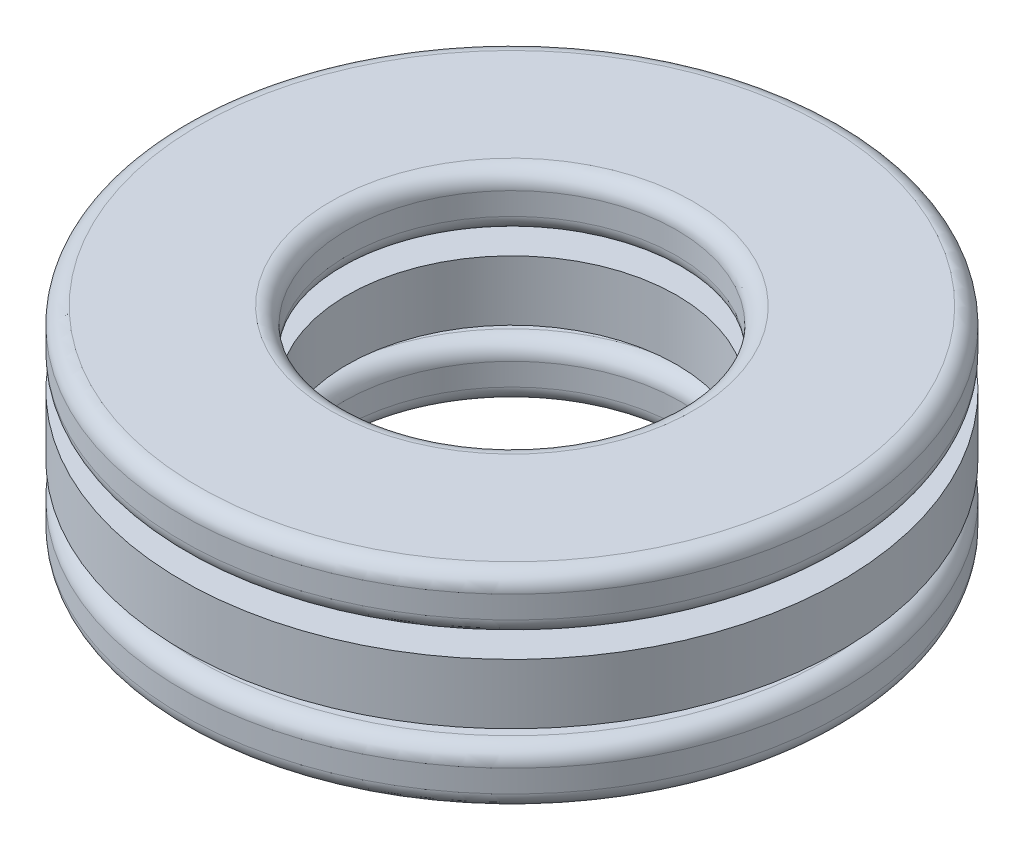
from build123d import *

# Parameters (mm, degrees)
SKETCH1_W         = 4
SKETCH1_H         = 1.458333334
CIRPATTERN1_COUNT = 6
CIRPATTERN1_ANGLE = 300
CIRPATTERN2_COUNT = 6


with BuildPart() as part:
    # Sketch1 → Revolve1 (revolve)
    with BuildSketch(Plane(origin=(0, 0, 0), x_dir=(0, 0, -1), z_dir=(1, 0, 0))):
        with Locations((-6, 0)):
            Rectangle(SKETCH1_W, SKETCH1_H)
    revolve(axis=Axis((0, -3.5, 0), (0, 1, 0)))

    # Sketch3 → Cut-Revolve1 (revolve, cut)
    with BuildSketch(Plane(origin=(0, 0, 0), x_dir=(0, 0, -1), z_dir=(1, 0, 0))):
        with BuildLine():
            Line((-6, 1.166666667), (-6, -1.166666667))
            ThreePointArc((-6, -1.166666667), (-7.166666667, 0), (-6, 1.166666667))
        make_face()
    cut_revolve1 = revolve(axis=Axis((0, 1.166666667, 6), (0, -1, 0)), mode=Mode.SUBTRACT)

    # CirPattern2: Cut-Revolve1 ×6 about axis
    cirpattern2_axis = Axis((0, 0, 0), (0, 1, 0))
    for i in range(1, CIRPATTERN2_COUNT):
        add(cut_revolve1.rotate(cirpattern2_axis, i * 360 / CIRPATTERN2_COUNT), mode=Mode.SUBTRACT)


with BuildPart() as body_2:
    # Sketch2 → Revolve2 (revolve)
    with BuildSketch(Plane(origin=(0, 0, 0), x_dir=(0, 0, -1), z_dir=(1, 0, 0))):
        with BuildLine():
            Line((-6, 1.166666667), (-6, -1.166666667))
            ThreePointArc((-6, -1.166666667), (-7.166666667, 0), (-6, 1.166666667))
        make_face()
    revolve(axis=Axis((0, 1.166666667, 6), (0, -1, 0)))


with BuildPart() as cirpattern1_1:
    # CirPattern1: pattern copy
    add(body_2.part.rotate(Axis((0, 3.5, 0), (0, -1, 0)), 1 * CIRPATTERN1_ANGLE / (CIRPATTERN1_COUNT - 1)))


with BuildPart() as cirpattern1_2:
    # CirPattern1: pattern copy
    add(body_2.part.rotate(Axis((0, 3.5, 0), (0, -1, 0)), 2 * CIRPATTERN1_ANGLE / (CIRPATTERN1_COUNT - 1)))


with BuildPart() as cirpattern1_3:
    # CirPattern1: pattern copy
    add(body_2.part.rotate(Axis((0, 3.5, 0), (0, -1, 0)), 3 * CIRPATTERN1_ANGLE / (CIRPATTERN1_COUNT - 1)))


with BuildPart() as cirpattern1_4:
    # CirPattern1: pattern copy
    add(body_2.part.rotate(Axis((0, 3.5, 0), (0, -1, 0)), 4 * CIRPATTERN1_ANGLE / (CIRPATTERN1_COUNT - 1)))


with BuildPart() as cirpattern1_5:
    # CirPattern1: pattern copy
    add(body_2.part.rotate(Axis((0, 3.5, 0), (0, -1, 0)), 5 * CIRPATTERN1_ANGLE / (CIRPATTERN1_COUNT - 1)))


with BuildPart() as body_8:
    # Sketch4 → Revolve3 (revolve)
    with BuildSketch(Plane(origin=(0, 0, 0), x_dir=(0, 0, -1), z_dir=(1, 0, 0))):
        with BuildLine():
            Line((-7.6, 2.5), (-4.4, 2.5))
            ThreePointArc((-4.4, 2.5), (-4.117157288, 2.382842712), (-4, 2.1))
            Line((-4, 2.1), (-4, 1.558333333))
            ThreePointArc((-4, 1.558333333), (-4.117157288, 1.275490621), (-4.4, 1.158333333))
            Line((-4.4, 1.158333333), (-7.6, 1.158333333))
            ThreePointArc((-7.6, 1.158333333), (-7.882842712, 1.275490621), (-8, 1.558333333))
            Line((-8, 1.558333333), (-8, 2.1))
            ThreePointArc((-8, 2.1), (-7.882842712, 2.382842712), (-7.6, 2.5))
        make_face()
        with BuildLine():
            Line((-7.6, -2.5), (-4.5, -2.5))
            ThreePointArc((-4.5, -2.5), (-4.217157288, -2.382842712), (-4.1, -2.1))
            Line((-4.1, -2.1), (-4.1, -1.558333333))
            ThreePointArc((-4.1, -1.558333333), (-4.217157288, -1.275490621), (-4.5, -1.158333333))
            Line((-4.5, -1.158333333), (-7.6, -1.158333333))
            ThreePointArc((-7.6, -1.158333333), (-7.882842712, -1.275490621), (-8, -1.558333333))
            Line((-8, -1.558333333), (-8, -2.1))
            ThreePointArc((-8, -2.1), (-7.882842712, -2.382842712), (-7.6, -2.5))
        make_face()
    revolve(axis=Axis((0, -3.5, 0), (0, 1, 0)))


solid = Compound([part.part, body_2.part, cirpattern1_1.part, cirpattern1_2.part, cirpattern1_3.part, cirpattern1_4.part, cirpattern1_5.part, body_8.part])
